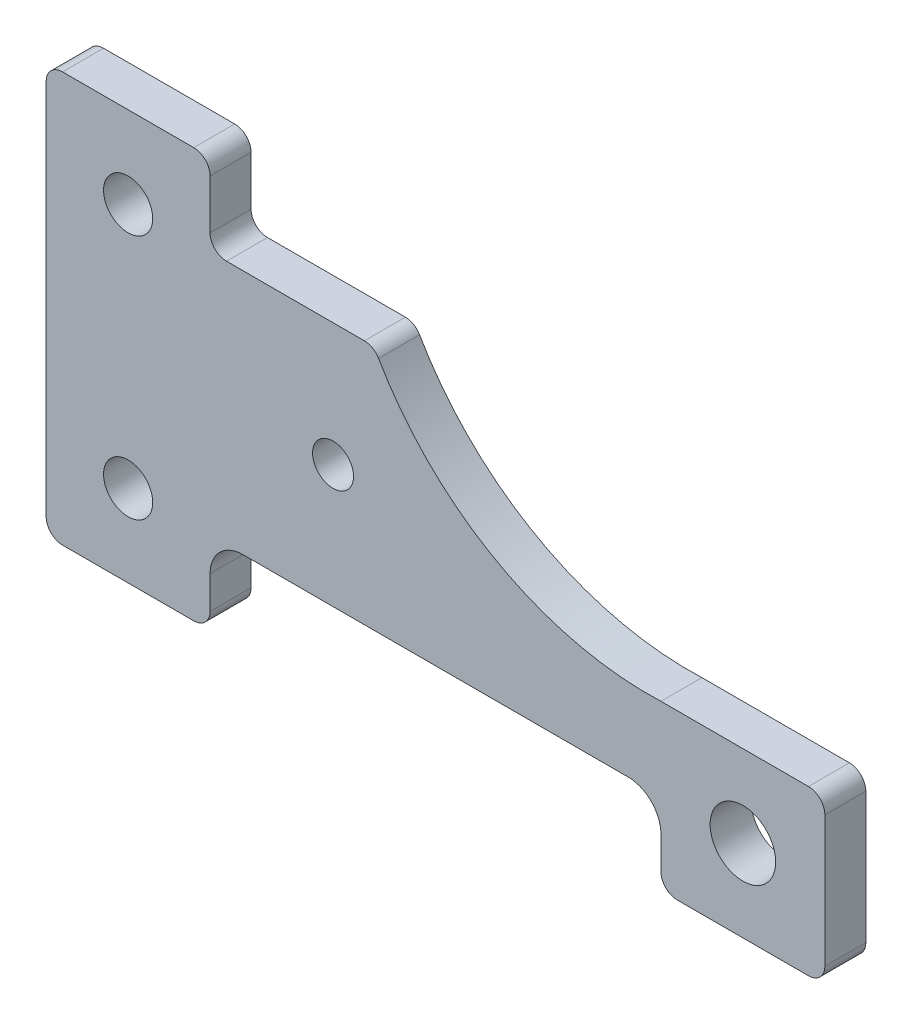
from build123d import *

# Parameters (mm, degrees)
IZIM1_R                     = 30
IZIM1_R_2                   = 25
IZIM1_R_3                   = 40
Y_KSEKLIK_EKSTR_ZYON1_DEPTH = 50


with BuildPart() as part:
    # Çizim1 → Yükseklik-Ekstrüzyon1 (new body)
    with BuildSketch(Plane.XY):
        with BuildLine():
            Line((200, 20), (200, 60))
            ThreePointArc((200, 60), (211.715728753, 88.284271247), (240, 100))
            Line((240, 100), (710, 100))
            ThreePointArc((710, 100), (738.284271247, 88.284271247), (750, 60))
            Line((750, 60), (750, 20))
            ThreePointArc((750, 20), (755.857864376, 5.857864376), (770, 0))
            Line((770, 0), (930, 0))
            ThreePointArc((930, 0), (944.142135624, 5.857864376), (950, 20))
            Line((950, 20), (950, 180))
            ThreePointArc((950, 180), (944.142135624, 194.142135624), (930, 200))
            Line((930, 200), (750, 200))
            ThreePointArc((750, 200), (551.290675458, 246.959096298), (405.571126809, 389.984847569))
            ThreePointArc((405.571126809, 389.984847569), (398.249452654, 397.316133393), (388.241879306, 400))
            Line((388.241879306, 400), (220, 400))
            ThreePointArc((220, 400), (205.857864376, 405.857864376), (200, 420))
            Line((200, 420), (200, 480))
            ThreePointArc((200, 480), (194.142135624, 494.142135624), (180, 500))
            Line((180, 500), (20, 500))
            ThreePointArc((20, 500), (5.857864376, 494.142135624), (0, 480))
            Line((0, 480), (0, 20))
            ThreePointArc((0, 20), (5.857864376, 5.857864376), (20, 0))
            Line((20, 0), (180, 0))
            ThreePointArc((180, 0), (194.142135624, 5.857864376), (200, 20))
        make_face()
        with Locations((100, 400)):
            Circle(IZIM1_R, mode=Mode.SUBTRACT)
        with Locations((100, 100)):
            Circle(IZIM1_R, mode=Mode.SUBTRACT)
        with Locations((350, 250)):
            Circle(IZIM1_R_2, mode=Mode.SUBTRACT)
        with Locations((850, 100)):
            Circle(IZIM1_R_3, mode=Mode.SUBTRACT)
    extrude(amount=Y_KSEKLIK_EKSTR_ZYON1_DEPTH)


solid = part.part
